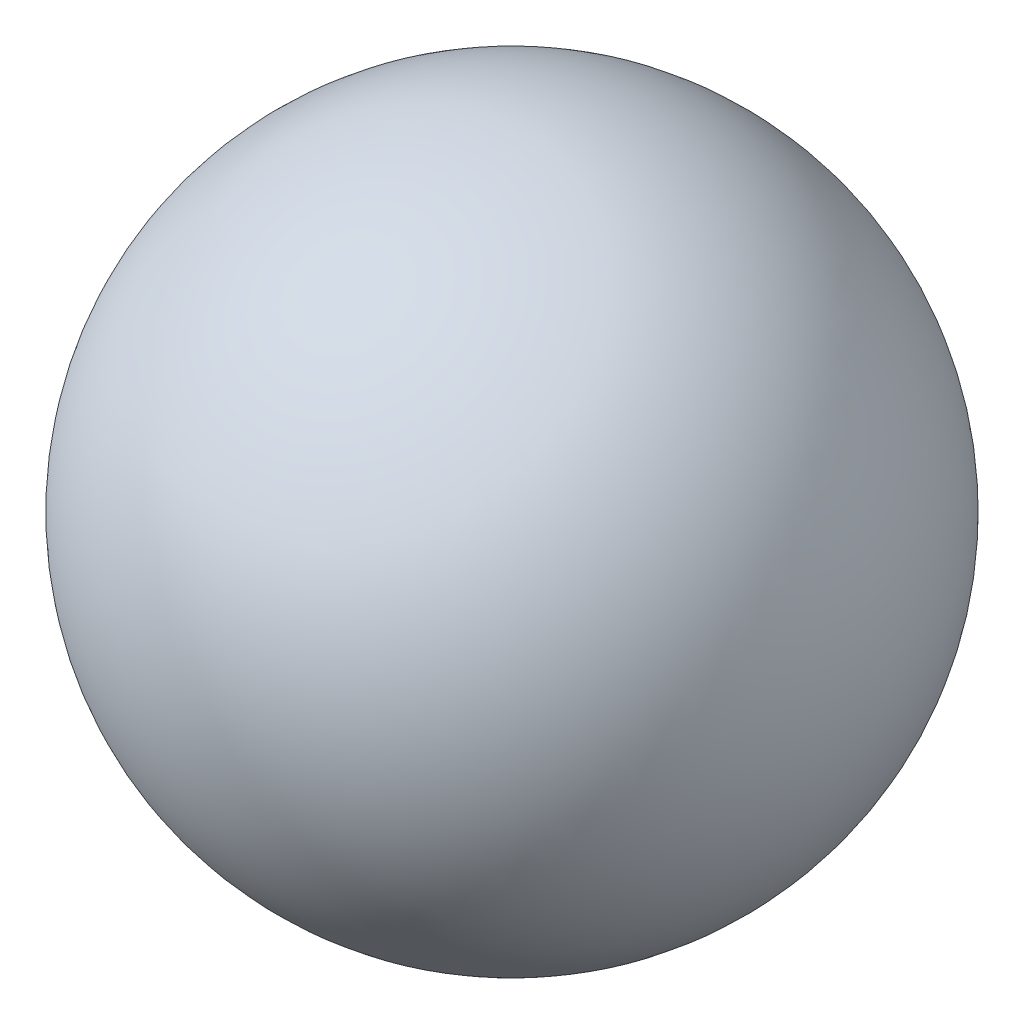
from build123d import *


with BuildPart() as part:
    # 草图1 → 旋转1 (revolve)
    with BuildSketch(Plane.XY):
        with BuildLine():
            Line((0, -20), (0, 20))
            ThreePointArc((0, 20), (-20, 0), (0, -20))
        make_face()
    revolve(axis=Axis((0, 0, 0), (0, 1, 0)))


solid = part.part
